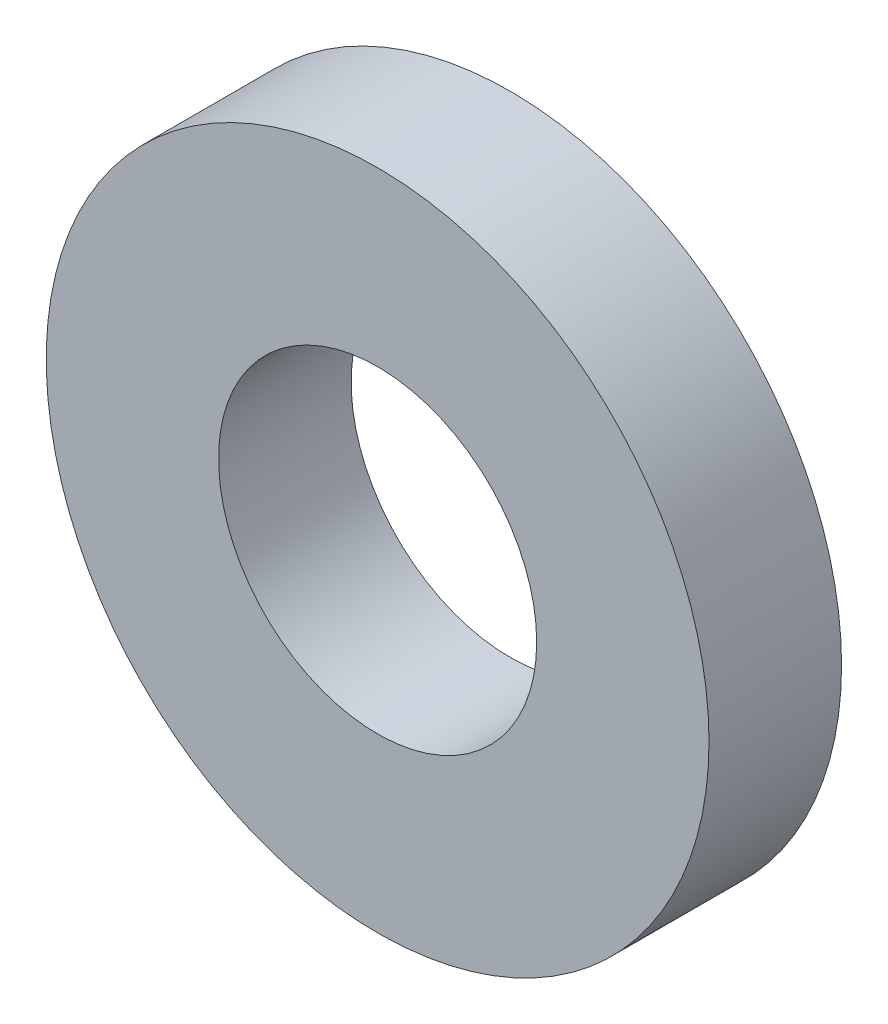
from build123d import *

# Parameters (mm, degrees)
SKETCH1_R           = 3.175
SKETCH1_R_2         = 1.524
BOSS_EXTRUDE1_DEPTH = 1.27


with BuildPart() as part:
    # Sketch1 → Boss-Extrude1 (new body)
    with BuildSketch(Plane.XY):
        Circle(SKETCH1_R)
        Circle(SKETCH1_R_2, mode=Mode.SUBTRACT)
    extrude(amount=BOSS_EXTRUDE1_DEPTH)


solid = part.part
